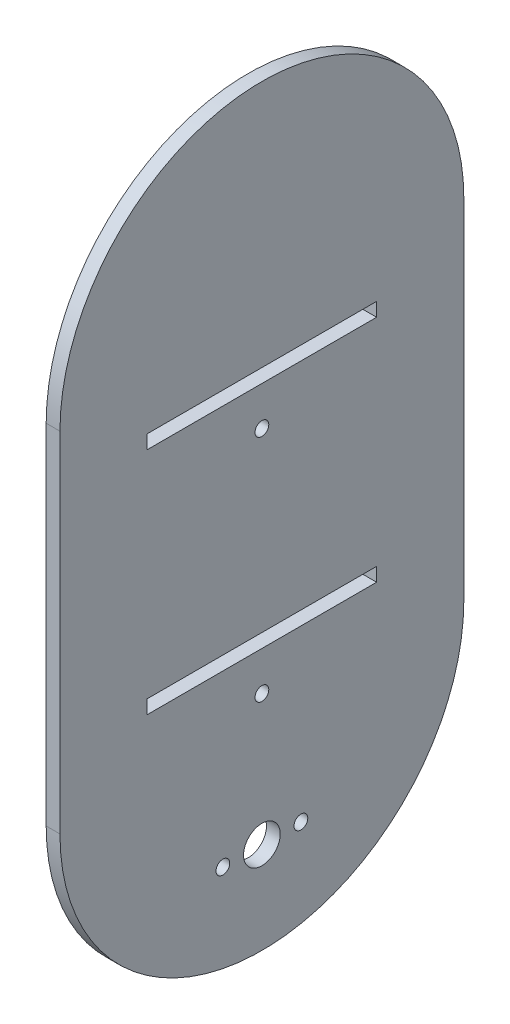
from build123d import *

# Parameters (mm, degrees)
SKETCH1_R           = 1.5
SKETCH1_R_2         = 4
SKETCH1_W           = 50
SKETCH1_H           = 3
BOSS_EXTRUDE1_DEPTH = 3


with BuildPart() as part:
    # Sketch1 → Boss-Extrude1 (new body)
    with BuildSketch(Plane(origin=(0, 0, 0), x_dir=(0, 0, -1), z_dir=(1, 0, 0))):
        with BuildLine():
            Line((-44, 0), (-44, -76))
            ThreePointArc((-44, -76), (0, -120), (44, -76))
            Line((44, -76), (44, 0))
            ThreePointArc((44, 0), (0, 44), (-44, 0))
        make_face()
        with Locations((0, -21.5)):
            Circle(SKETCH1_R, mode=Mode.SUBTRACT)
        with Locations((0, -71.5)):
            Circle(SKETCH1_R, mode=Mode.SUBTRACT)
        with Locations((0, -100)):
            Circle(SKETCH1_R_2, mode=Mode.SUBTRACT)
        with Locations((-8.5, -100)):
            Circle(SKETCH1_R, mode=Mode.SUBTRACT)
        with Locations((8.5, -100)):
            Circle(SKETCH1_R, mode=Mode.SUBTRACT)
        with Locations((0, -11.5)):
            Rectangle(SKETCH1_W, SKETCH1_H, mode=Mode.SUBTRACT)
        with Locations((0, -61.5)):
            Rectangle(SKETCH1_W, SKETCH1_H, mode=Mode.SUBTRACT)
    extrude(amount=BOSS_EXTRUDE1_DEPTH)


solid = part.part
